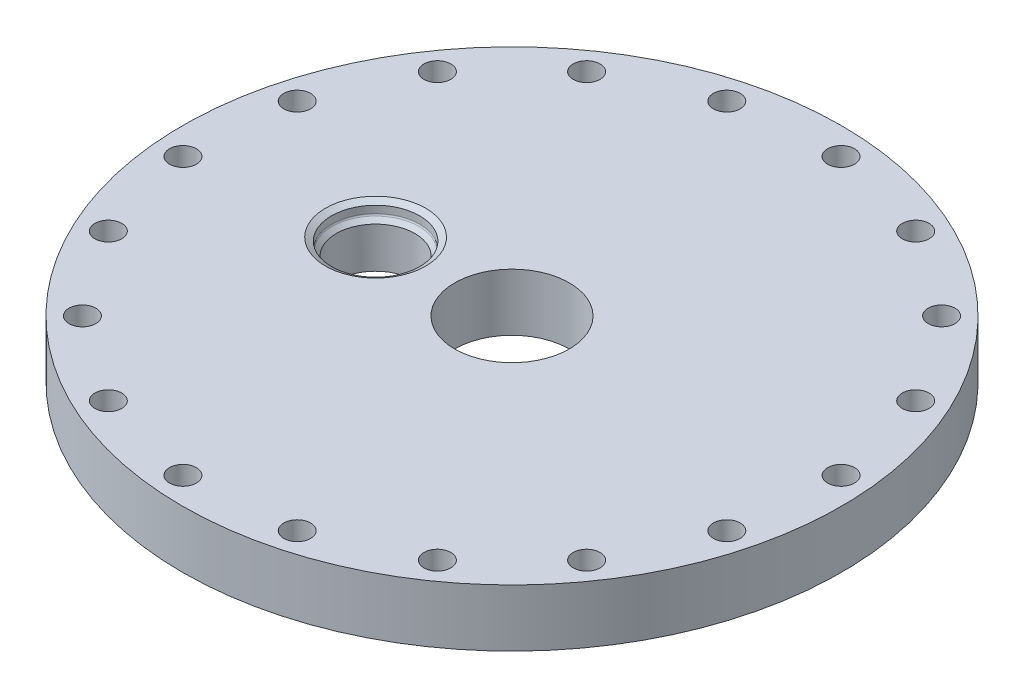
from build123d import *

# Parameters (mm, degrees)
TOP_PLATE_DIAMETER_R           = 73.025
TOP_PLATE_EXTRUDE_DEPTH        = 12.7
FUEL_PORT_CLEARANCE_DIAMETER_R = 12.7
FUEL_PORT_CLEARANCE_HOLE_DEPTH = 105.050907012
ASSEMBLY_BOLT_REACH            = 106.051
ASSEMBLY_BOLT_DIAMETER_R       = 2.97688
CIRPATTERN1_COUNT              = 18
LOX_PORT_REACH                 = 106.051
SKETCH7_R                      = 8.7122


with BuildPart() as part:
    # Top Plate Diameter → Top Plate Extrude (new body)
    with BuildSketch(Plane(origin=(0, 0, 0), x_dir=(1, 0, 0), z_dir=(0, 1, 0))):
        Circle(TOP_PLATE_DIAMETER_R)
    extrude(amount=TOP_PLATE_EXTRUDE_DEPTH)

    # Fuel Port Clearance Diameter → Fuel Port Clearance Hole (cut, through all)
    with BuildSketch(Plane(origin=(0, 12.7, 0), x_dir=(1, 0, 0), z_dir=(0, 1, 0))):
        Circle(FUEL_PORT_CLEARANCE_DIAMETER_R)
    extrude(amount=-FUEL_PORT_CLEARANCE_HOLE_DEPTH, mode=Mode.SUBTRACT)

    # Assembly Bolt Diameter → Assembly Bolt (cut, up to next)
    with BuildSketch(Plane(origin=(0, 12.7, 0), x_dir=(1, 0, 0), z_dir=(0, 1, 0)), mode=Mode.PRIVATE) as assembly_bolt_sk1:
        with Locations((-65.016467368, 17.421109926)):
            Circle(ASSEMBLY_BOLT_DIAMETER_R)
    assembly_bolt_tool1 = extrude(assembly_bolt_sk1.sketch, amount=-ASSEMBLY_BOLT_REACH, mode=Mode.PRIVATE) & part.part
    assembly_bolt = assembly_bolt_tool1.solids().sort_by_distance((-65.016467, 12.7, -17.42111))[0]
    add(assembly_bolt, mode=Mode.SUBTRACT)

    # CirPattern1: Assembly Bolt ×18 about axis
    cirpattern1_axis = Axis((0, 12.7, 0), (0, -1, 0))
    for i in range(1, CIRPATTERN1_COUNT):
        add(assembly_bolt.rotate(cirpattern1_axis, i * 360 / CIRPATTERN1_COUNT), mode=Mode.SUBTRACT)

    # Sketch7 → LOX Port (cut, up to next)
    with BuildSketch(Plane(origin=(0, 12.7, 0), x_dir=(1, 0, 0), z_dir=(0, 1, 0)), mode=Mode.PRIVATE) as lox_port_sk1:
        with Locations((-30.226, 0)):
            Circle(SKETCH7_R)
    lox_port_tool1 = extrude(lox_port_sk1.sketch, amount=-LOX_PORT_REACH, mode=Mode.PRIVATE) & part.part
    add(lox_port_tool1.solids().sort_by_distance((-30.226, 12.7, 0))[0], mode=Mode.SUBTRACT)

    # Sketch9 → Cut-Revolve1 (revolve, cut)
    with BuildSketch(Plane.XY):
        with BuildLine():
            Line((-41.3385, 12.7), (-39.9923, 11.922771068))
            Line((-39.9923, 11.922771068), (-39.9923, 10.3124))
            ThreePointArc((-39.9923, 10.3124), (-39.953630803, 10.117996816), (-39.843510245, 9.953189755))
            Line((-39.843510245, 9.953189755), (-38.9382, 9.04787951))
            Line((-38.9382, 9.04787951), (-38.9382, 12.7))
            Line((-38.9382, 12.7), (-41.3385, 12.7))
        make_face()
    revolve(axis=Axis((-30.226, -7.468881995, 0), (0, 1, 0)), mode=Mode.SUBTRACT)


solid = part.part
